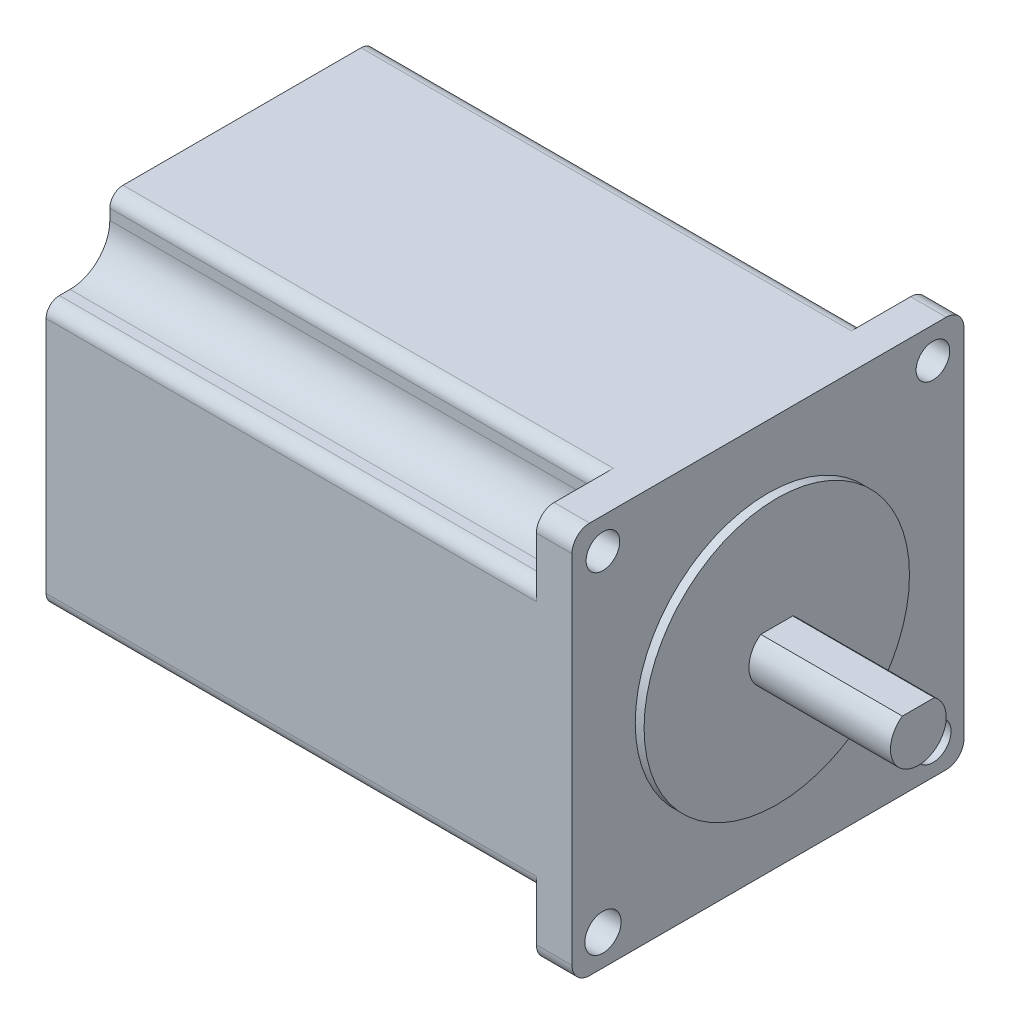
from build123d import *

# Parameters (mm, degrees)
SKETCH1_W           = 56.261
SKETCH1_H           = 56.261
BOSS_EXTRUDE2_DEPTH = 75.4888
SKETCH2_R           = 19.05
BOSS_EXTRUDE3_DEPTH = 1.27
CUT_EXTRUDE1_DEPTH  = 70.3834
FILLET1_R           = 2.54
FILLET2_R           = 1.905
SKETCH4_R           = 2.413
SKETCH4_R_2         = 2.6035
CUT_EXTRUDE2_DEPTH  = 5.1054
BOSS_EXTRUDE4_DEPTH = 20.32
SKETCH6_W           = 11.049
SKETCH6_H           = 11.43
SKETCH6_R           = 2.8575
BOSS_EXTRUDE5_DEPTH = 1.524
SKETCH7_R           = 0.8255
BOSS_EXTRUDE6_DEPTH = 12.7


with BuildPart() as part:
    # Sketch1 → Boss-Extrude2 (new body)
    with BuildSketch(Plane(origin=(0, 0, 0), x_dir=(0, 0, -1), z_dir=(1, 0, 0))):
        Rectangle(SKETCH1_W, SKETCH1_H)
    extrude(amount=BOSS_EXTRUDE2_DEPTH)

    # Sketch2 → Boss-Extrude3 (add)
    with BuildSketch(Plane(origin=(75.4888, 0, 0), x_dir=(0, 0, -1), z_dir=(1, 0, 0))):
        Circle(SKETCH2_R)
    extrude(amount=BOSS_EXTRUDE3_DEPTH)

    # Sketch3 → Cut-Extrude1 (cut)
    with BuildSketch(Plane.ZY):
        with BuildLine():
            Line((28.1305, 18.9865), (24.7015, 18.9865))
            ThreePointArc((24.7015, 18.9865), (20.660384746, 20.660384746), (18.9865, 24.7015))
            Line((18.9865, 24.7015), (18.9865, 28.1305))
            Line((18.9865, 28.1305), (28.1305, 28.1305))
            Line((28.1305, 28.1305), (28.1305, 18.9865))
        make_face()
        with BuildLine():
            Line((-28.1305, 28.1305), (-18.9865, 28.1305))
            Line((-18.9865, 28.1305), (-18.9865, 24.7015))
            ThreePointArc((-18.9865, 24.7015), (-20.660384746, 20.660384746), (-24.7015, 18.9865))
            Line((-24.7015, 18.9865), (-28.1305, 18.9865))
            Line((-28.1305, 18.9865), (-28.1305, 28.1305))
        make_face()
        with BuildLine():
            Line((18.9865, -28.1305), (18.9865, -24.7015))
            ThreePointArc((18.9865, -24.7015), (20.660384746, -20.660384746), (24.7015, -18.9865))
            Line((24.7015, -18.9865), (28.1305, -18.9865))
            Line((28.1305, -18.9865), (28.1305, -28.1305))
            Line((28.1305, -28.1305), (18.9865, -28.1305))
        make_face()
        with BuildLine():
            Line((-28.1305, -18.9865), (-24.7015, -18.9865))
            ThreePointArc((-24.7015, -18.9865), (-20.660384746, -20.660384746), (-18.9865, -24.7015))
            Line((-18.9865, -24.7015), (-18.9865, -28.1305))
            Line((-18.9865, -28.1305), (-28.1305, -28.1305))
            Line((-28.1305, -28.1305), (-28.1305, -18.9865))
        make_face()
    extrude(amount=-CUT_EXTRUDE1_DEPTH, mode=Mode.SUBTRACT)

    # Fillet1
    fillet1_edges = [part.edges().sort_by_distance(p)[0] for p in [
        (72.9361, -28.1305, -28.1305),
        (72.9361, -28.1305, 28.1305),
        (72.9361, 28.1305, 28.1305),
        (72.9361, 28.1305, -28.1305),
    ]]
    fillet(fillet1_edges, radius=FILLET1_R)

    # Fillet2
    fillet2_edges = [part.edges().sort_by_distance(p)[0] for p in [
        (35.1917, -28.1305, -18.9865),
        (35.1917, -18.9865, -28.1305),
        (35.1917, -18.9865, 28.1305),
        (35.1917, -28.1305, 18.9865),
        (35.1917, 28.1305, 18.9865),
        (35.1917, 18.9865, 28.1305),
        (35.1917, 18.9865, -28.1305),
        (35.1917, 28.1305, -18.9865),
    ]]
    fillet(fillet2_edges, radius=FILLET2_R)

    # Sketch4 → Cut-Extrude2 (cut)
    with BuildSketch(Plane.ZY.offset(-70.3834)):
        with Locations((-23.6855, 23.6855)):
            Circle(SKETCH4_R)
        with Locations((23.6855, 23.6855)):
            Circle(SKETCH4_R)
        with Locations((23.6855, -23.6855)):
            Circle(SKETCH4_R_2)
        with Locations((-23.6855, -23.6855)):
            Circle(SKETCH4_R_2)
    extrude(amount=-CUT_EXTRUDE2_DEPTH, mode=Mode.SUBTRACT)

    # Sketch5 → Boss-Extrude4 (add)
    with BuildSketch(Plane(origin=(76.7588, 0, 0), x_dir=(0, 0, -1), z_dir=(1, 0, 0))):
        with BuildLine():
            Line((-2.295189031, 3.2766), (2.295189031, 3.2766))
            ThreePointArc((2.295189031, 3.2766), (0, -4.0005), (-2.295189031, 3.2766))
        make_face()
    extrude(amount=BOSS_EXTRUDE4_DEPTH)

    # Sketch6 → Boss-Extrude5 (add)
    with BuildSketch(Plane.XZ.offset(28.1305)):
        with Locations((5.5245, 0)):
            Rectangle(SKETCH6_W, SKETCH6_H)
        with Locations((6.858, 0)):
            Circle(SKETCH6_R, mode=Mode.SUBTRACT)
    extrude(amount=BOSS_EXTRUDE5_DEPTH)

    # Sketch7 → Boss-Extrude6 (add)
    with BuildSketch(Plane.XZ.offset(28.1305)):
        with Locations((6.858, 1.285488676)):
            Circle(SKETCH7_R)
        with Locations((8.143488676, 0)):
            Circle(SKETCH7_R)
        with Locations((6.858, -1.285488676)):
            Circle(SKETCH7_R)
        with Locations((5.572511324, 0)):
            Circle(SKETCH7_R)
    extrude(amount=BOSS_EXTRUDE6_DEPTH)


solid = part.part
